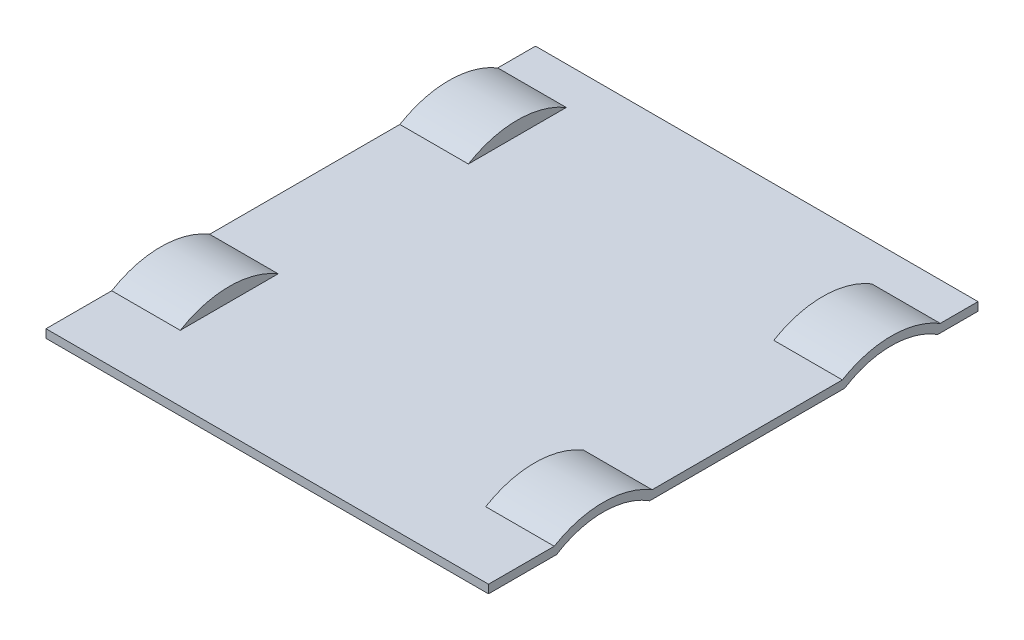
from build123d import *

# Parameters (mm, degrees)
SKETCH2_W           = 175
SKETCH2_H           = 3
BOSS_EXTRUDE1_DEPTH = 158.2
BOSS_EXTRUDE2_DEPTH = 24.5
CUT_EXTRUDE1_DEPTH  = 22


with BuildPart() as part:
    # Sketch2 → Boss-Extrude1 (new body)
    with BuildSketch(Plane(origin=(0, 0, 0), x_dir=(0, 0, -1), z_dir=(1, 0, 0))):
        with Locations((87.5, 1.5)):
            Rectangle(SKETCH2_W, SKETCH2_H)
    extrude(amount=-BOSS_EXTRUDE1_DEPTH)

    # Sketch2_5 → Boss-Extrude2 (add)
    with BuildSketch(Plane(origin=(0, 0, 0), x_dir=(0, 0, -1), z_dir=(1, 0, 0))):
        with BuildLine():
            ThreePointArc((58.500785697, 3), (41, 7.85), (23.499214303, 3))
            Line((23.499214303, 3), (58.500785697, 3))
        make_face()
        with BuildLine():
            ThreePointArc((161.500785697, 3), (144, 7.85), (126.499214303, 3))
            Line((126.499214303, 3), (161.500785697, 3))
        make_face()
    boss_extrude2 = extrude(amount=-BOSS_EXTRUDE2_DEPTH)

    # Sketch2_7 → Cut-Extrude1 (cut)
    with BuildSketch(Plane(origin=(0, 0, 0), x_dir=(0, 0, -1), z_dir=(1, 0, 0))):
        with BuildLine():
            Line((24.351351406, 0), (57.648648594, 0))
            ThreePointArc((57.648648594, 0), (41, 4.85), (24.351351406, 0))
        make_face()
        with BuildLine():
            Line((127.351351406, 0), (160.648648594, 0))
            ThreePointArc((160.648648594, 0), (144, 4.85), (127.351351406, 0))
        make_face()
    cut_extrude1 = extrude(amount=-CUT_EXTRUDE1_DEPTH, mode=Mode.SUBTRACT)

    # Mirror1: Boss-Extrude2, Cut-Extrude1 across plane
    add(boss_extrude2.mirror(Plane(origin=(-79.1, 0, 0), x_dir=(0, 0, 1), z_dir=(1, 0, 0))))
    add(cut_extrude1.mirror(Plane(origin=(-79.1, 0, 0), x_dir=(0, 0, 1), z_dir=(1, 0, 0))), mode=Mode.SUBTRACT)


solid = part.part
